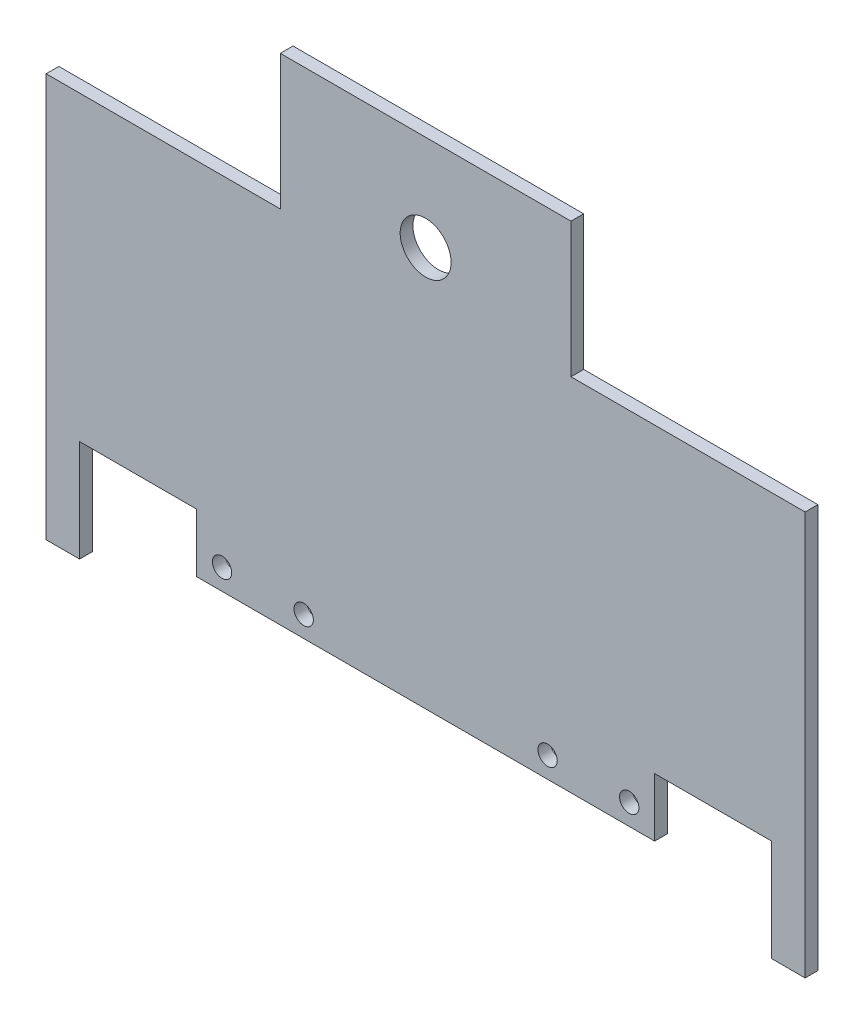
from build123d import *

# Parameters (mm, degrees)
SKETCH1_R           = 2.413
SKETCH1_R_2         = 6.35
BOSS_EXTRUDE1_DEPTH = 3.175


with BuildPart() as part:
    # Sketch1 → Boss-Extrude1 (new body)
    with BuildSketch(Plane.XY):
        Polygon((92.594576982, -6.877947448), (92.594576982, 60.126165821), (34.151950775, 60.126165821), (34.151950775, 93.757031287), (-38.373257593, 93.757031287), (-38.373257593, 60.126165821), (-96.8158838, 60.126165821), (-96.8158838, -6.877947448), (-96.8158838, -40.590224659), (-88.470653409, -40.590224659), (-88.470653409, -15.190224659), (-59.260653409, -15.190224659), (-59.260653409, -29.792684659), (55.039346591, -29.792684659), (55.039346591, -15.190224659), (84.249346591, -15.190224659), (84.249346591, -40.590224659), (92.594576982, -40.590224659), align=None)
        with Locations((48.689346591, -24.567904659)):
            Circle(SKETCH1_R, mode=Mode.SUBTRACT)
        with Locations((28.322015094, -24.567904659)):
            Circle(SKETCH1_R, mode=Mode.SUBTRACT)
        with Locations((-32.543321912, -24.567904659)):
            Circle(SKETCH1_R, mode=Mode.SUBTRACT)
        with Locations((-52.910653409, -24.567904659)):
            Circle(SKETCH1_R, mode=Mode.SUBTRACT)
        with Locations((-2.110653409, 69.892524061)):
            Circle(SKETCH1_R_2, mode=Mode.SUBTRACT)
    extrude(amount=BOSS_EXTRUDE1_DEPTH)


solid = part.part
